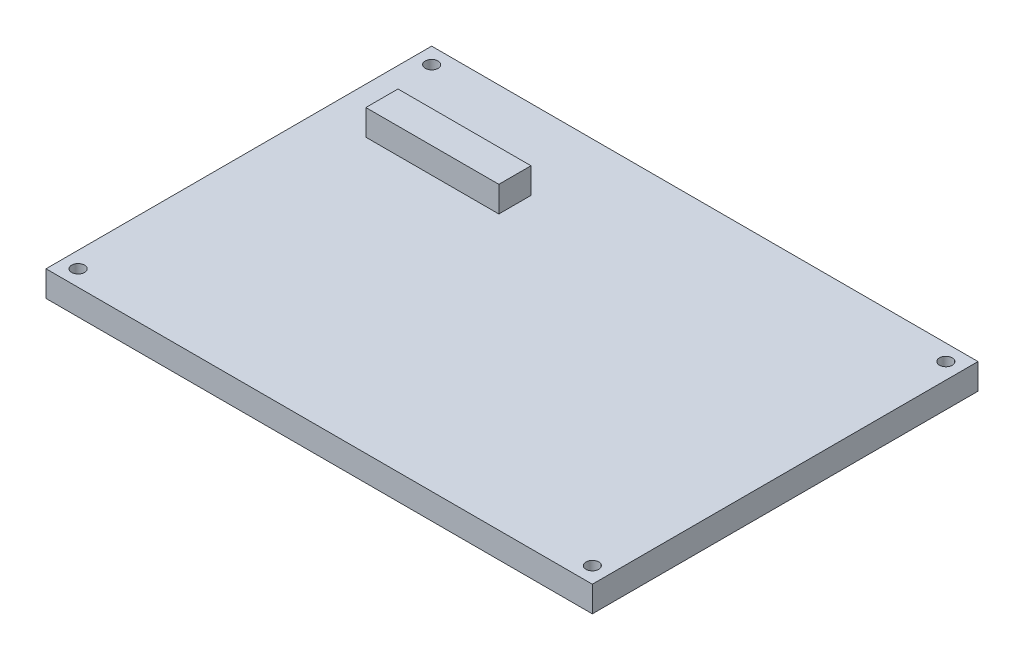
from build123d import *

# Parameters (mm, degrees)
SKETCH1_W           = 170
SKETCH1_H           = 120
BOSS_EXTRUDE1_DEPTH = 8
SKETCH2_W           = 41.380626675
SKETCH2_H           = 10
BOSS_EXTRUDE2_DEPTH = 8
SKETCH3_R           = 2
CUT_EXTRUDE1_DEPTH  = 8


with BuildPart() as part:
    # Sketch1 → Boss-Extrude1 (new body)
    with BuildSketch(Plane(origin=(0, 0, 0), x_dir=(1, 0, 0), z_dir=(0, 1, 0))):
        Rectangle(SKETCH1_W, SKETCH1_H)
    extrude(amount=BOSS_EXTRUDE1_DEPTH)

    # Sketch2 → Boss-Extrude2 (add)
    with BuildSketch(Plane(origin=(-17.791513114, 8, -1.374929401), x_dir=(1, 0, 0), z_dir=(0, 1, 0))):
        with Locations((-32.208486886, 28.840032215)):
            Rectangle(SKETCH2_W, SKETCH2_H)
    extrude(amount=BOSS_EXTRUDE2_DEPTH)

    # Sketch3 → Cut-Extrude1 (cut)
    with BuildSketch(Plane(origin=(0, 8, 0), x_dir=(1, 0, 0), z_dir=(0, 1, 0))):
        with Locations((-80, 55)):
            Circle(SKETCH3_R)
        with Locations((-80, -55)):
            Circle(SKETCH3_R)
        with Locations((80, 55)):
            Circle(SKETCH3_R)
        with Locations((80, -55)):
            Circle(SKETCH3_R)
    extrude(amount=-CUT_EXTRUDE1_DEPTH, mode=Mode.SUBTRACT)


solid = part.part
